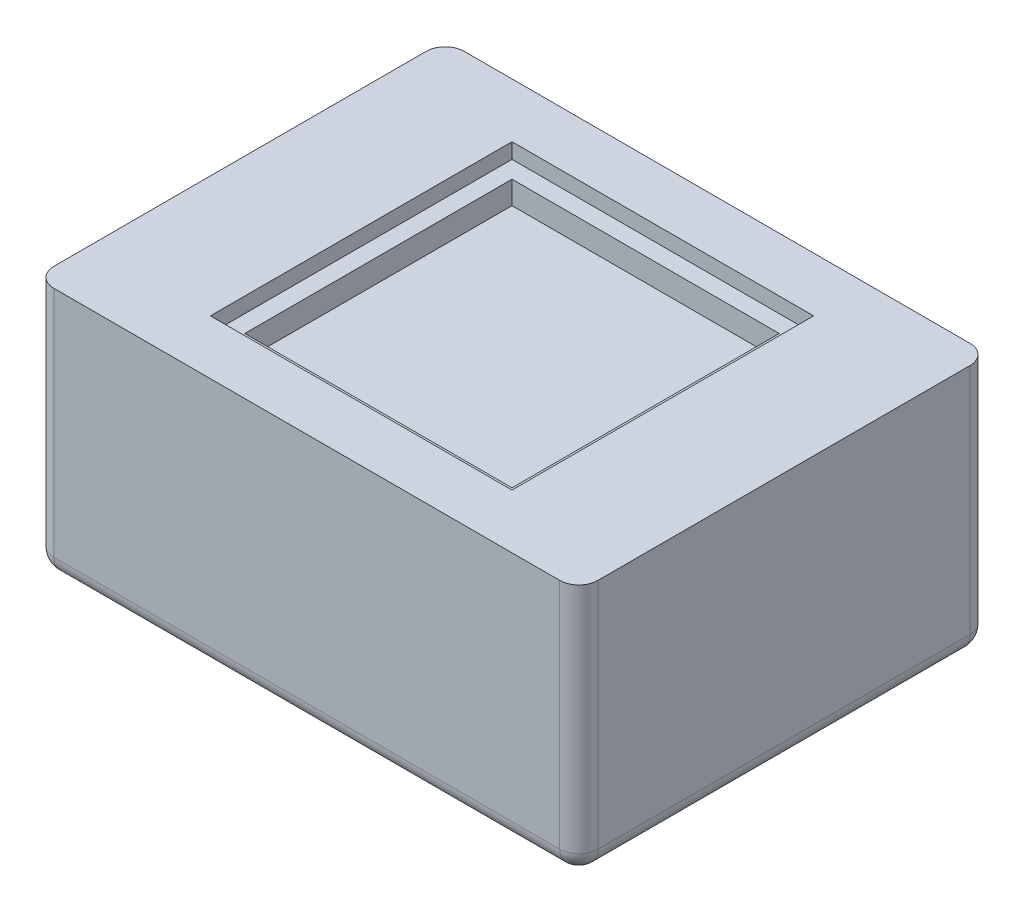
from build123d import *

# Parameters (mm, degrees)
SKETCH_1_W          = 28.5
SKETCH_1_H          = 21.5
EXTRUDE_1_DEPTH     = 13.2
FILLET_1_R          = 1
SKETCH_3_W          = 14
SKETCH_3_H          = 14
CUT_EXTRUDE_2_DEPTH = 2
SKETCH_4_W          = 15.8
SKETCH_4_H          = 15.8
CUT_EXTRUDE_3_DEPTH = 0.8
FILLET_2_R          = 1


with BuildPart() as part:
    # 草图1 → 凸台-拉伸1 (new body)
    with BuildSketch(Plane(origin=(0, 0, 0), x_dir=(1, 0, 0), z_dir=(0, 1, 0))):
        Rectangle(SKETCH_1_W, SKETCH_1_H)
    extrude(amount=EXTRUDE_1_DEPTH)

    # 圆角1
    fillet_1_edges = [part.edges().sort_by_distance(p)[0] for p in [
        (14.25, 6.6, 10.75),
        (-14.25, 6.6, 10.75),
        (-14.25, 6.6, -10.75),
        (14.25, 6.6, -10.75),
    ]]
    fillet(fillet_1_edges, radius=FILLET_1_R)

    # 草图3 → 切除-拉伸2 (cut)
    with BuildSketch(Plane(origin=(0, 13.2, 0), x_dir=(1, 0, 0), z_dir=(0, 1, 0))):
        Rectangle(SKETCH_3_W, SKETCH_3_H)
    extrude(amount=-CUT_EXTRUDE_2_DEPTH, mode=Mode.SUBTRACT)

    # 草图4 → 切除-拉伸3 (cut)
    with BuildSketch(Plane(origin=(0, 13.2, 0), x_dir=(1, 0, 0), z_dir=(0, 1, 0))):
        Rectangle(SKETCH_4_W, SKETCH_4_H)
    extrude(amount=-CUT_EXTRUDE_3_DEPTH, mode=Mode.SUBTRACT)

    # 圆角2
    fillet_2_edges = [part.edges().sort_by_distance(p)[0] for p in [
        (14.25, 0, 0),
        (0, 0, 10.75),
        (-14.25, 0, 0),
        (0, 0, -10.75),
        (13.957106781, 0, -10.457106781),
        (-13.957106781, 0, -10.457106781),
        (-13.957106781, 0, 10.457106781),
        (13.957106781, 0, 10.457106781),
    ]]
    fillet(fillet_2_edges, radius=FILLET_2_R)


solid = part.part
